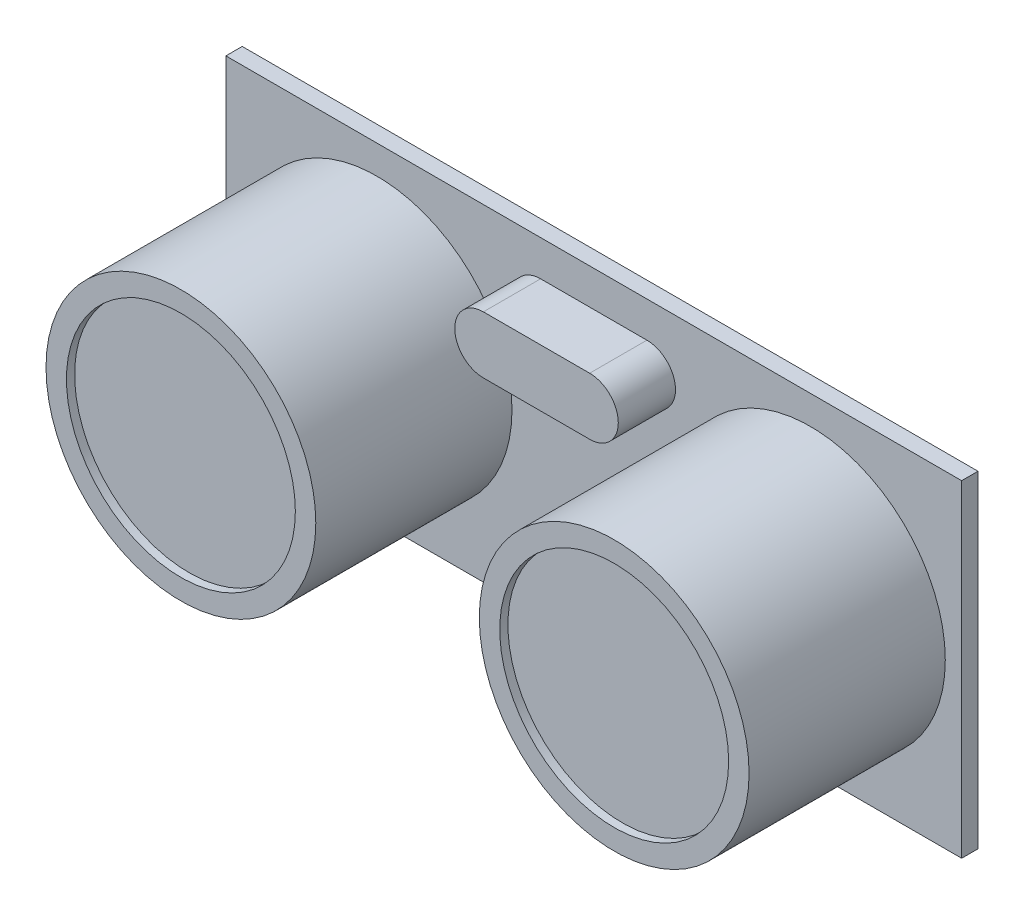
from build123d import *

# Parameters (mm, degrees)
ESBO_O1_W                = 45
ESBO_O1_H                = 20
RESSALTO_EXTRUS_O1_DEPTH = 1
ESBO_O2_R                = 8.25
RESSALTO_EXTRUS_O2_DEPTH = 12
ESBO_O3_R                = 7
CORTE_EXTRUS_O1_DEPTH    = 0.5
RESSALTO_EXTRUS_O5_DEPTH = 3.5
ESBO_O7_W                = 1.9
ESBO_O7_H                = 2
ESBO_O7_W_2              = 1.8
RESSALTO_EXTRUS_O6_DEPTH = 2
ESBO_O9_W                = 10
ESBO_O9_H                = 0.1
CORTE_EXTRUS_O2_DEPTH    = 2
ESBO_O10_W               = 1
ESBO_O10_H               = 1
RESSALTO_EXTRUS_O7_DEPTH = 2
ESBO_O11_W               = 1
ESBO_O11_H               = 1
ESBO_O11_H_2             = 0.967747288
RESSALTO_EXTRUS_O8_DEPTH = 4


with BuildPart() as part:
    # Esboço1 → Ressalto-extrusão1 (new body)
    with BuildSketch(Plane.XY):
        with Locations((22.5, 10)):
            Rectangle(ESBO_O1_W, ESBO_O1_H)
    extrude(amount=RESSALTO_EXTRUS_O1_DEPTH)

    # Esboço2 → Ressalto-extrusão2 (add)
    with BuildSketch(Plane.XY.offset(1)):
        with Locations((9.25, 10)):
            Circle(ESBO_O2_R)
        with Locations((35.75, 10)):
            Circle(ESBO_O2_R)
    extrude(amount=RESSALTO_EXTRUS_O2_DEPTH)

    # Esboço3 → Corte-extrusão1 (cut)
    with BuildSketch(Plane.XY.offset(13)):
        with Locations((9.25, 10)):
            Circle(ESBO_O3_R)
        with Locations((35.75, 10)):
            Circle(ESBO_O3_R)
    extrude(amount=-CORTE_EXTRUS_O1_DEPTH, mode=Mode.SUBTRACT)

    # Esboço6 → Ressalto-extrusão5 (add)
    with BuildSketch(Plane.XY.offset(1)):
        with BuildLine():
            Line((25.75, 17.816758405), (19.25, 17.816758405))
            ThreePointArc((19.25, 17.816758405), (17.5, 16.066758405), (19.25, 14.316758405))
            Line((19.25, 14.316758405), (25.75, 14.316758405))
            ThreePointArc((25.75, 14.316758405), (27.5, 16.066758405), (25.75, 17.816758405))
        make_face()
    extrude(amount=RESSALTO_EXTRUS_O5_DEPTH)

    # Esboço7 → Ressalto-extrusão6 (add)
    with BuildSketch(Plane(origin=(0, 0, 0), x_dir=(-1, 0, 0), z_dir=(0, 0, -1))):
        with Locations((-26.55, 1)):
            Rectangle(ESBO_O7_W, ESBO_O7_H)
        with Locations((-24.5, 1)):
            Rectangle(ESBO_O7_W_2, ESBO_O7_H)
        with Locations((-22.5, 1)):
            Rectangle(ESBO_O7_W_2, ESBO_O7_H)
        with Locations((-20.5, 1)):
            Rectangle(ESBO_O7_W_2, ESBO_O7_H)
        with Locations((-18.45, 1)):
            Rectangle(ESBO_O7_W, ESBO_O7_H)
    extrude(amount=RESSALTO_EXTRUS_O6_DEPTH)

    # Esboço9 → Corte-extrusão2 (cut)
    with BuildSketch(Plane(origin=(0, 0, -2), x_dir=(-1, 0, 0), z_dir=(0, 0, -1))):
        with Locations((-22.5, 0.05)):
            Rectangle(ESBO_O9_W, ESBO_O9_H)
    extrude(amount=-CORTE_EXTRUS_O2_DEPTH, mode=Mode.SUBTRACT)

    # Esboço10 → Ressalto-extrusão7 (add)
    with BuildSketch(Plane(origin=(0, 0, -2), x_dir=(-1, 0, 0), z_dir=(0, 0, -1))):
        with Locations((-24.5, 1.05)):
            Rectangle(ESBO_O10_W, ESBO_O10_H)
        with Locations((-26.55, 1.05)):
            Rectangle(ESBO_O10_W, ESBO_O10_H)
        with Locations((-22.472435469, 1.05)):
            Rectangle(ESBO_O10_W, ESBO_O10_H)
        with Locations((-20.46939422, 1.05)):
            Rectangle(ESBO_O10_W, ESBO_O10_H)
        with Locations((-18.471440092, 1.05)):
            Rectangle(ESBO_O10_W, ESBO_O10_H)
    extrude(amount=RESSALTO_EXTRUS_O7_DEPTH)

    # Esboço11 → Ressalto-extrusão8 (add)
    with BuildSketch(Plane.XZ.offset(-0.55)):
        with Locations((26.55, -3.5)):
            Rectangle(ESBO_O11_W, ESBO_O11_H)
        with Locations((24.5, -3.5)):
            Rectangle(ESBO_O11_W, ESBO_O11_H)
        with Locations((22.472435469, -3.516126356)):
            Rectangle(ESBO_O11_W, ESBO_O11_H_2)
        with Locations((20.46939422, -3.516126356)):
            Rectangle(ESBO_O11_W, ESBO_O11_H_2)
        with Locations((18.471440092, -3.516126356)):
            Rectangle(ESBO_O11_W, ESBO_O11_H_2)
    extrude(amount=RESSALTO_EXTRUS_O8_DEPTH)


solid = part.part
